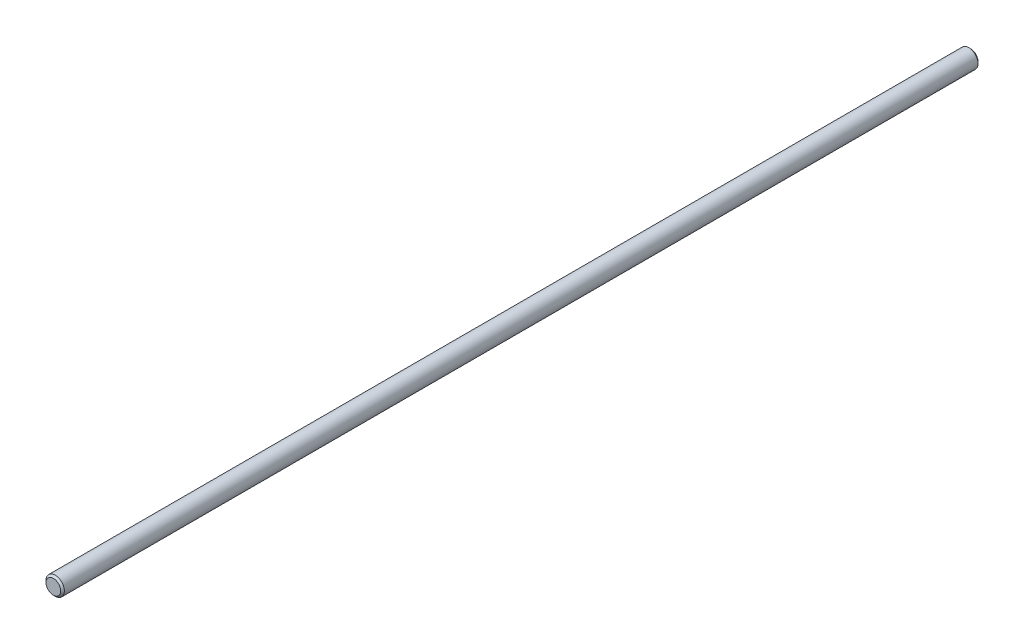
from build123d import *

# Parameters (mm, degrees)
SKETCH1_R           = 10
BOSS_EXTRUDE1_DEPTH = 1000
CHAMFER1_SIZE       = 2


with BuildPart() as part:
    # Sketch1 → Boss-Extrude1 (new body)
    with BuildSketch(Plane.XY):
        Circle(SKETCH1_R)
    extrude(amount=BOSS_EXTRUDE1_DEPTH)

    # Chamfer1
    chamfer1_edges = [part.edges().sort_by_distance(p)[0] for p in [
        (-10, 0, 0),
        (-10, 0, 1000),
    ]]
    chamfer(chamfer1_edges, length=CHAMFER1_SIZE)


solid = part.part
